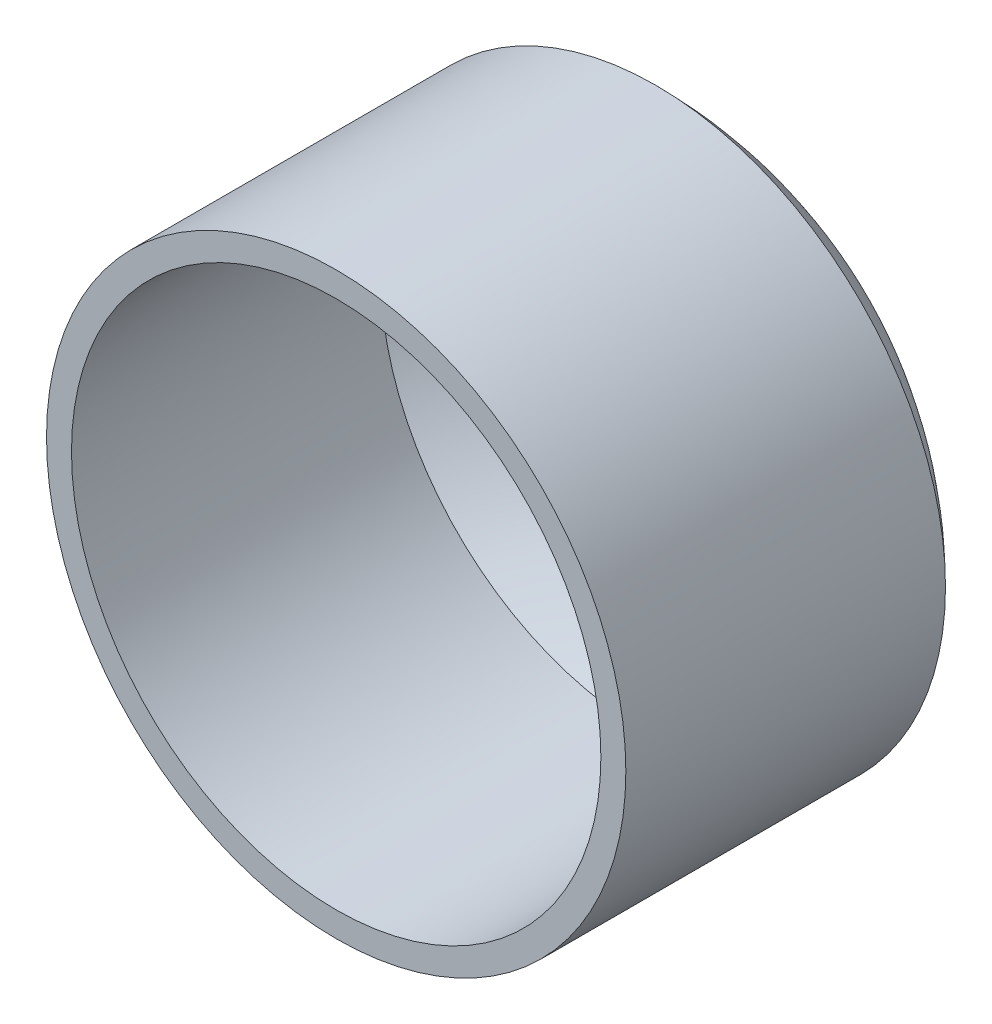
from build123d import *

# Parameters (mm, degrees)
SKETCH1_R           = 92.075
BOSS_EXTRUDE1_DEPTH = 101.6
SHELL1_T            = -7.9375


with BuildPart() as part:
    # Sketch1 → Boss-Extrude1 (new body)
    with BuildSketch(Plane.XY):
        Circle(SKETCH1_R)
    extrude(amount=BOSS_EXTRUDE1_DEPTH)

    # Sketch2 → Revolve1 (revolve)
    with BuildSketch(Plane(origin=(0, 0, 0), x_dir=(0, 0, -1), z_dir=(1, 0, 0))):
        with BuildLine():
            Line((0, 0), (38.1, 0))
            ThreePointArc((38.1, 0), (28.198839221, 49.823226574), (0, 92.075))
            Line((0, 92.075), (0, 0))
        make_face()
    revolve(axis=Axis((0, 0, 0), (0, 0, -1)))

    # Shell1
    shell1_openings = [part.faces().sort_by_distance(p)[0] for p in [
        (0, 0, 101.6),
    ]]
    offset(amount=SHELL1_T, openings=shell1_openings)


solid = part.part
